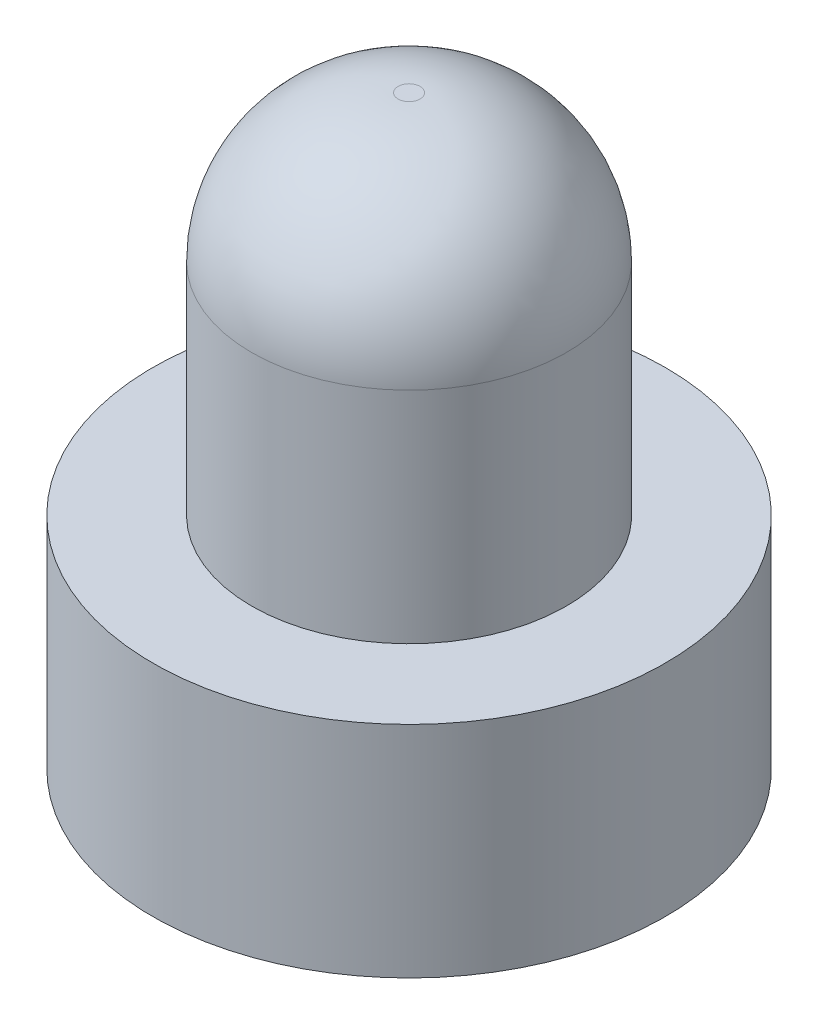
from build123d import *

# Parameters (mm, degrees)
SKETCH1_R           = 2.15
BOSS_EXTRUDE1_DEPTH = 5
SKETCH2_R           = 3.5
BOSS_EXTRUDE2_DEPTH = 3
SKETCH3_R           = 2
CUT_EXTRUDE1_DEPTH  = 3
FILLET1_R           = 2


with BuildPart() as part:
    # Sketch1 → Boss-Extrude1 (new body)
    with BuildSketch(Plane(origin=(0, 0, 0), x_dir=(1, 0, 0), z_dir=(0, 1, 0))):
        Circle(SKETCH1_R)
    extrude(amount=BOSS_EXTRUDE1_DEPTH)

    # Sketch2 → Boss-Extrude2 (add)
    with BuildSketch(Plane.XZ):
        Circle(SKETCH2_R)
    extrude(amount=BOSS_EXTRUDE2_DEPTH)

    # Sketch3 → Cut-Extrude1 (cut)
    with BuildSketch(Plane.XZ.offset(3)):
        Circle(SKETCH3_R)
    extrude(amount=-CUT_EXTRUDE1_DEPTH, mode=Mode.SUBTRACT)

    # Fillet1
    fillet1_edges = [part.edges().sort_by_distance(p)[0] for p in [
        (-2.15, 5, 0),
    ]]
    fillet(fillet1_edges, radius=FILLET1_R)


solid = part.part
